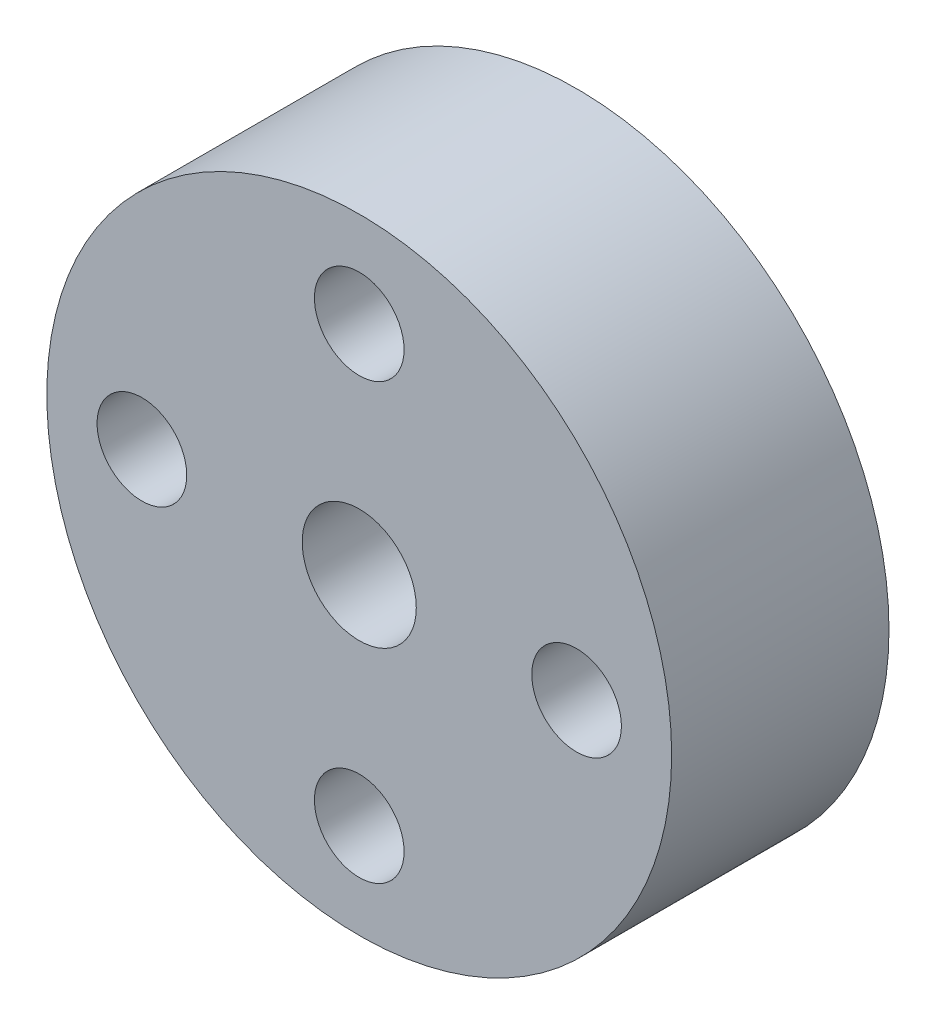
from build123d import *

# Parameters (mm, degrees)
SKETCH_1_R      = 11.5
SKETCH_1_R_2    = 1.65
SKETCH_1_R_3    = 2.1
EXTRUDE_1_DEPTH = 8


with BuildPart() as part:
    # 草圖1 → 填料-伸長1 (new body)
    with BuildSketch(Plane.XY):
        Circle(SKETCH_1_R)
        with Locations((0, 8)):
            Circle(SKETCH_1_R_2, mode=Mode.SUBTRACT)
        with Locations((8, 0)):
            Circle(SKETCH_1_R_2, mode=Mode.SUBTRACT)
        with Locations((0, -8)):
            Circle(SKETCH_1_R_2, mode=Mode.SUBTRACT)
        with Locations((-8, 0)):
            Circle(SKETCH_1_R_2, mode=Mode.SUBTRACT)
        Circle(SKETCH_1_R_3, mode=Mode.SUBTRACT)
    extrude(amount=EXTRUDE_1_DEPTH)


solid = part.part
